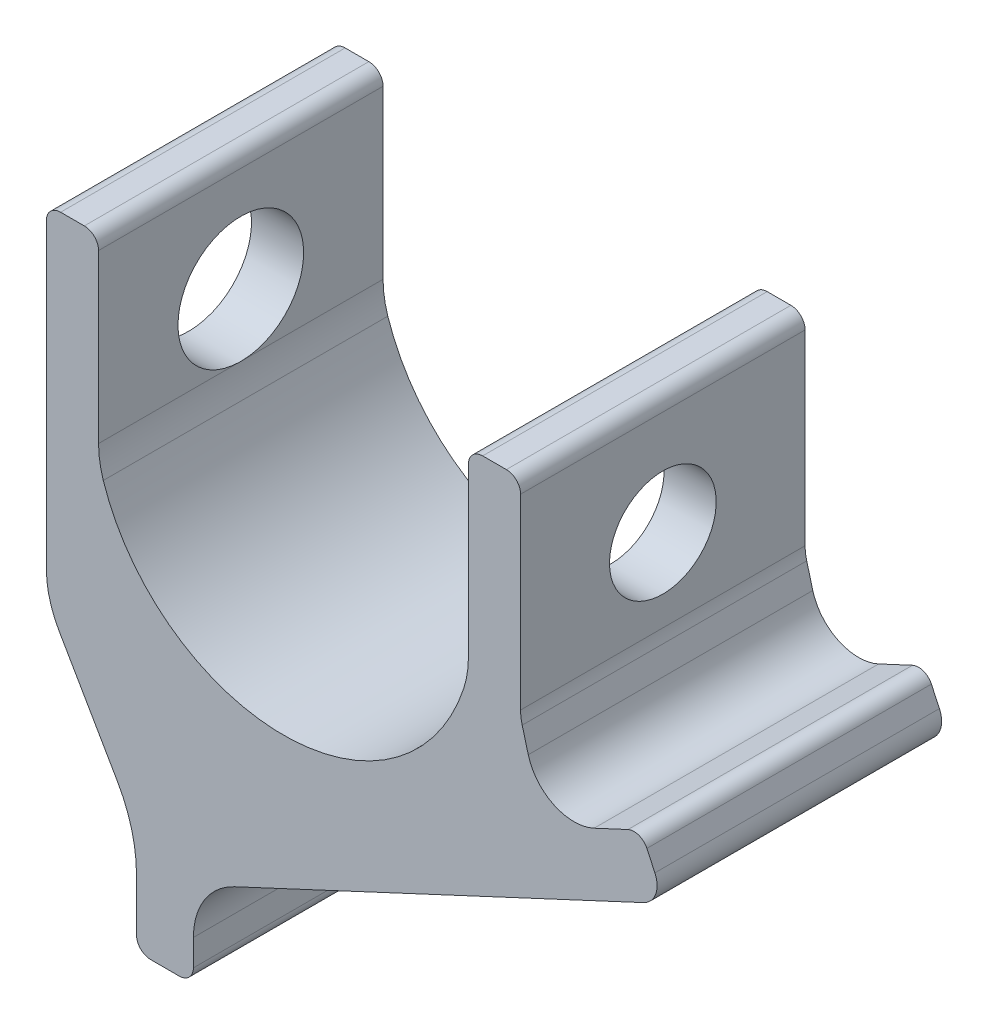
from build123d import *

# Parameters (mm, degrees)
BASE_EXTRUDE_DEPTH = 30


with BuildPart() as part:
    # Sketch1 → Base-Extrude (new body, symmetric)
    with BuildSketch(Plane.XY):
        with BuildLine():
            Line((39, -13.244998), (39, 22))
            ThreePointArc((39, 22), (39.87868, 24.12132), (42, 25))
            Line((42, 25), (47, 25))
            ThreePointArc((47, 25), (49.12132, 24.12132), (50, 22))
            Line((50, 22), (50, -17.41181))
            ThreePointArc((50, -17.41181), (50.085551, -18.717071), (50.340742, -20))
            Line((50.340742, -20), (51.61865, -24.769217))
            ThreePointArc((51.61865, -24.769217), (57.051725, -31.244104), (65.50409, -31.244104))
            Line((65.50409, -31.244104), (72.645011, -27.914239))
            ThreePointArc((72.645011, -27.914239), (74.938926, -27.814084), (76.631789, -29.365307))
            Line((76.631789, -29.365307), (78.322262, -32.990538))
            ThreePointArc((78.322262, -32.990538), (78.489186, -36.81373), (75.903815, -39.635168))
            Line((75.903815, -39.635168), (-10.339274, -79.850981))
            ThreePointArc((-10.339274, -79.850981), (-16.650872, -85.386104), (-19, -93.445598))
            Line((-19, -93.445598), (-19, -99))
            ThreePointArc((-19, -99), (-19.87868, -101.12132), (-22, -102))
            Line((-22, -102), (-28, -102))
            ThreePointArc((-28, -102), (-30.12132, -101.12132), (-31, -99))
            Line((-31, -99), (-31, -87.947441))
            ThreePointArc((-31, -87.947441), (-32.022225, -80.18287), (-35.019238, -72.947441))
            Line((-35.019238, -72.947441), (-47.320508, -51.641016))
            ThreePointArc((-47.320508, -51.641016), (-49.318517, -46.817397), (-50, -41.641016))
            Line((-50, -41.641016), (-50, 22))
            ThreePointArc((-50, 22), (-49.12132, 24.12132), (-47, 25))
            Line((-47, 25), (-42, 25))
            ThreePointArc((-42, 25), (-39.87868, 24.12132), (-39, 22))
            Line((-39, 22), (-39, -13.244998))
            ThreePointArc((-39, -13.244998), (-38.748418, -16.407276), (-38, -19.489996))
            ThreePointArc((-38, -19.489996), (-23.456344, -39.400616), (0, -47))
            ThreePointArc((0, -47), (23.456344, -39.400616), (38, -19.489996))
            ThreePointArc((38, -19.489996), (38.748418, -16.407276), (39, -13.244998))
        make_face()
    extrude(amount=BASE_EXTRUDE_DEPTH, both=True)

    # Sketch4 → Udboring ø26.5/ø22.5 (revolve, cut)
    with BuildSketch(Plane.XY):
        Polygon((50, 11.25), (0, 11.25), (0, 13.25), (-50, 13.25), (-50, 0), (0, 0), (50, 0), align=None)
    revolve(axis=Axis((0, 0, 0), (1, 0, 0)), mode=Mode.SUBTRACT)


solid = part.part
